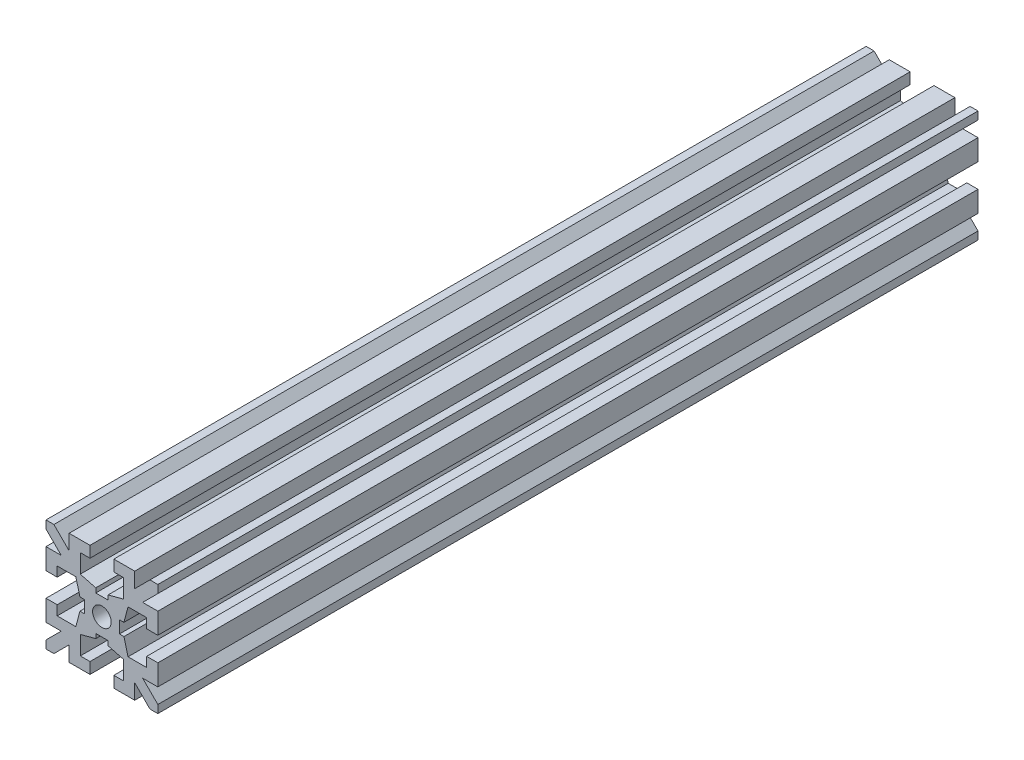
from build123d import *

# Parameters (mm, degrees)
RESSALTO_EXTRUS_O1_DEPTH   = 55
ESPELHAR2_COPY_1_DEPTH     = 55
ESBO_O2_R                  = 1.25
CORTE_EXTRUS_O1_DEPTH      = 1
CORTE_EXTRUS_O1_DEPTH_BACK = 111


with BuildPart() as part:
    # Esboço1 → Ressalto-extrusão1 (new body, symmetric)
    with BuildSketch(Plane.XY):
        Polygon((0, 2.35), (-0.825, 2.35), (-0.825, 2.95), (-2.9, 3.5), (-2.9, 6), (-1.6, 6), (-1.6, 7.5), (-4.4, 7.5), (-4.4, 5.460660172), (-6.439339828, 7.5), (-7.5, 7.5), (-7.5, 6.439339828), (-5.460660172, 4.4), (-7.5, 4.4), (-7.5, 1.6), (-6, 1.6), (-6, 2.9), (-3.5, 2.9), (-2.95, 0.825), (-2.35, 0.825), (-2.35, 0), (0, 0), align=None)
    ressalto_extrus_o1 = extrude(amount=RESSALTO_EXTRUS_O1_DEPTH, both=True)

    # Espelhar1: Ressalto-extrusão1 across plane
    add(ressalto_extrus_o1.mirror(Plane.ZX))

    # Espelhar2: Ressalto-extrusão1 across plane
    add(ressalto_extrus_o1.mirror(Plane(origin=(0, 0, 0), x_dir=(0, 0, 1), z_dir=(1, 0, 0))))

    # Espelhar2 copy 1 sketch → Espelhar2 copy 1 (add, symmetric)
    with BuildSketch(Plane(origin=(0, 0, 0), x_dir=(-1, 0, 0), z_dir=(0, 0, 1))):
        Polygon((0, 2.35), (-0.825, 2.35), (-0.825, 2.95), (-2.9, 3.5), (-2.9, 6), (-1.6, 6), (-1.6, 7.5), (-4.4, 7.5), (-4.4, 5.460660172), (-6.439339828, 7.5), (-7.5, 7.5), (-7.5, 6.439339828), (-5.460660172, 4.4), (-7.5, 4.4), (-7.5, 1.6), (-6, 1.6), (-6, 2.9), (-3.5, 2.9), (-2.95, 0.825), (-2.35, 0.825), (-2.35, 0), (0, 0), align=None)
    extrude(amount=ESPELHAR2_COPY_1_DEPTH, both=True)

    # Esboço2 → Corte-extrusão1 (cut, two sides)
    with BuildSketch(Plane.XY.offset(55)) as corte_extrus_o1_sk:
        Circle(ESBO_O2_R)
    extrude(amount=CORTE_EXTRUS_O1_DEPTH, mode=Mode.SUBTRACT)
    extrude(corte_extrus_o1_sk.sketch, amount=-CORTE_EXTRUS_O1_DEPTH_BACK, mode=Mode.SUBTRACT)


solid = part.part
